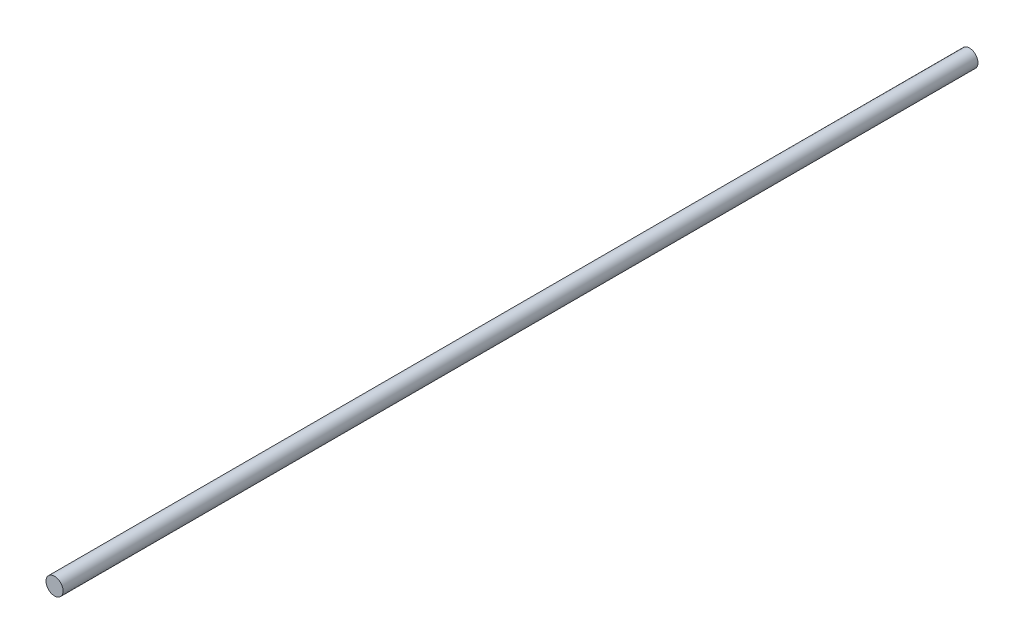
from build123d import *

# Parameters (mm, degrees)
SKETCH_1_R      = 4
EXTRUDE_1_DEPTH = 428


with BuildPart() as part:
    # 草图1 → 凸台-拉伸1 (new body)
    with BuildSketch(Plane.XY):
        Circle(SKETCH_1_R)
    extrude(amount=EXTRUDE_1_DEPTH)


solid = part.part
